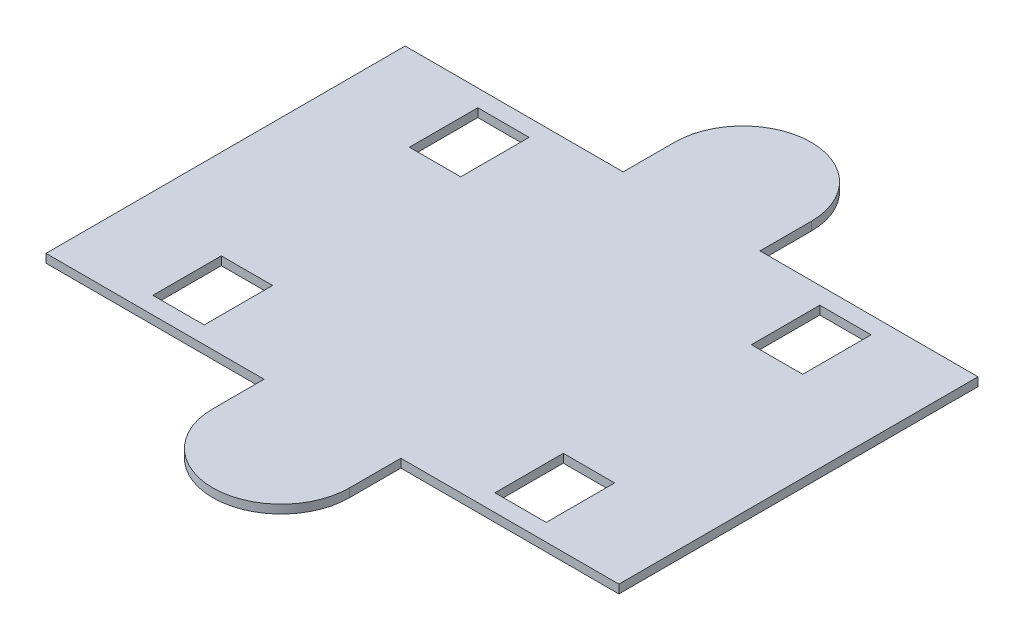
from build123d import *

# Parameters (mm, degrees)
SKETCH1_R           = 137.941576563
EXTRUDE1_DEPTH      = 3.175
SKETCH2_W           = 19.05
SKETCH2_H           = 25.4
EXTRUDE2_DEPTH      = 4.175
SKETCH3_OUTSIDE_W   = 355.918
SKETCH3_OUTSIDE_H   = 355.918
SKETCH3_OUTSIDE_W_2 = 212.725
SKETCH3_OUTSIDE_H_2 = 133.35
EXTRUDE3_DEPTH      = 4.175
EXTRUDE4_DEPTH      = 3.175


with BuildPart() as part:
    # Sketch1 → Extrude1 (new body)
    with BuildSketch(Plane(origin=(0, 0, 0), x_dir=(1, 0, 0), z_dir=(0, 1, 0))):
        with Locations(Location((0, 0, 0), (0, 0, 270))):  # turned: the seam where the file's is
            Circle(SKETCH1_R)
    extrude(amount=EXTRUDE1_DEPTH)

    # Sketch2 → Extrude2 (cut, through all)
    with BuildSketch(Plane(origin=(0, 3.175, 0), x_dir=(-1, 0, 0), z_dir=(0, 1, 0))):
        with Locations((63.5, -47.625)):
            Rectangle(SKETCH2_W, SKETCH2_H)
        with Locations((63.5, 47.625)):
            Rectangle(SKETCH2_W, SKETCH2_H)
        with Locations((-63.5, 47.625)):
            Rectangle(SKETCH2_W, SKETCH2_H)
        with Locations((-63.5, -47.625)):
            Rectangle(SKETCH2_W, SKETCH2_H)
    extrude(amount=-EXTRUDE2_DEPTH, mode=Mode.SUBTRACT)

    # Sketch3 outside → Extrude3 (cut, through all)
    with BuildSketch(Plane(origin=(0, 3.175, 0), x_dir=(1, 0, 0), z_dir=(0, 1, 0))):
        Rectangle(SKETCH3_OUTSIDE_W, SKETCH3_OUTSIDE_H)
        Rectangle(SKETCH3_OUTSIDE_W_2, SKETCH3_OUTSIDE_H_2, mode=Mode.SUBTRACT)
    extrude(amount=-EXTRUDE3_DEPTH, mode=Mode.SUBTRACT)

    # Sketch4 → Extrude4 (add, through all)
    with BuildSketch(Plane(origin=(0, 3.175, 0), x_dir=(-1, 0, 0), z_dir=(0, 1, 0))):
        with BuildLine():
            Line((-25.4, -66.675), (25.4, -66.675))
            Line((25.4, -66.675), (25.4, -85.725))
            ThreePointArc((25.4, -85.725), (0, -111.125), (-25.4, -85.725))
            Line((-25.4, -85.725), (-25.4, -66.675))
        make_face()
        with BuildLine():
            Line((25.4, 66.675), (25.4, 85.725))
            ThreePointArc((25.4, 85.725), (0, 111.125), (-25.4, 85.725))
            Line((-25.4, 85.725), (-25.4, 66.675))
            Line((-25.4, 66.675), (25.4, 66.675))
        make_face()
    extrude(amount=-EXTRUDE4_DEPTH)


solid = part.part
